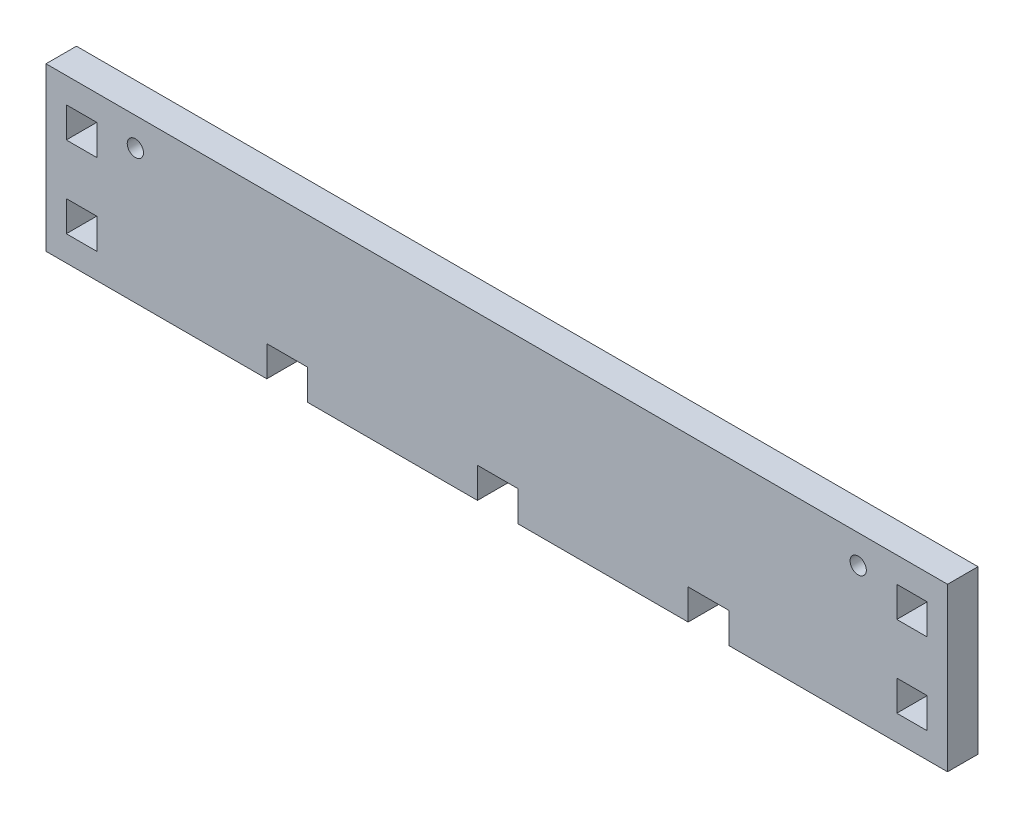
from build123d import *

# Parameters (mm, degrees)
SKETCH1_R           = 4
SKETCH1_W           = 15
SKETCH1_H           = 15
BOSS_EXTRUDE1_DEPTH = 15


with BuildPart() as part:
    # Sketch1 → Boss-Extrude1 (new body)
    with BuildSketch(Plane.XY):
        Polygon((0, 0), (0, 80), (444, 80), (444, 0), (336.25, 0), (336.25, 15), (316.25, 15), (316.25, 0), (232.5, 0), (232.5, 15), (212.5, 15), (212.5, 0), (128.75, 0), (128.75, 15), (108.75, 15), (108.75, 0), align=None)
        with Locations((44, 66)):
            Circle(SKETCH1_R, mode=Mode.SUBTRACT)
        with Locations(Location((400, 66, 0), (0, 0, 180))):  # turned: the seam where the file's is
            Circle(SKETCH1_R, mode=Mode.SUBTRACT)
        with Locations((17.5, 60)):
            Rectangle(SKETCH1_W, SKETCH1_H, mode=Mode.SUBTRACT)
        with Locations((17.5, 20)):
            Rectangle(SKETCH1_W, SKETCH1_H, mode=Mode.SUBTRACT)
        with Locations((426.5, 20)):
            Rectangle(SKETCH1_W, SKETCH1_H, mode=Mode.SUBTRACT)
        with Locations((426.5, 60)):
            Rectangle(SKETCH1_W, SKETCH1_H, mode=Mode.SUBTRACT)
    extrude(amount=BOSS_EXTRUDE1_DEPTH)


solid = part.part
